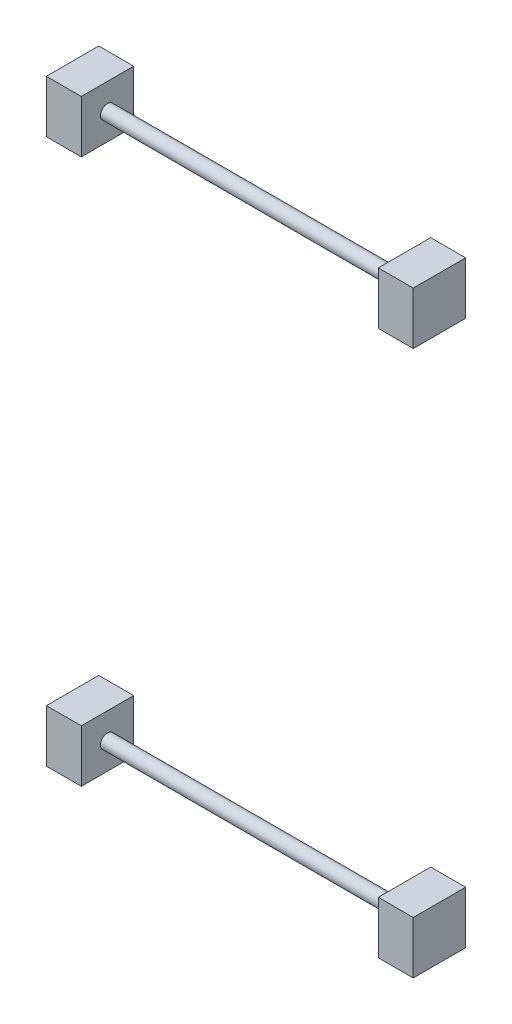
from build123d import *

# Parameters (mm, degrees)
SKETCH1_W           = 75
SKETCH1_H           = 75
SKETCH1_R           = 10
BOSS_EXTRUDE1_DEPTH = 50
LPATTERN1_COUNT     = 2
LPATTERN1_PITCH     = 475
SKETCH2_R           = 10
BOSS_EXTRUDE2_DEPTH = 525
LPATTERN2_COUNT     = 2
LPATTERN2_PITCH     = 780


with BuildPart() as part:
    # Sketch1 → Boss-Extrude1 (new body)
    with BuildSketch(Plane.ZY.offset(23475.561141738)):
        with Locations((40655.358832434, 5612.166693368)):
            Rectangle(SKETCH1_W, SKETCH1_H)
        with Locations((40655.358832434, 5612.166693368)):
            Circle(SKETCH1_R, mode=Mode.SUBTRACT)
    extrude(amount=-BOSS_EXTRUDE1_DEPTH)


with BuildPart() as lpattern1_1:
    # LPattern1: pattern copy
    add(part.part.moved(Location(Vector(1, 0, 0) * (1 * LPATTERN1_PITCH))))


with BuildPart() as part_1:
    add(part.part)

    add(lpattern1_1.part)  # Boss-Extrude2 merges LPattern1_1
    # Sketch2 → Boss-Extrude2 (add)
    with BuildSketch(Plane.ZY.offset(23475.561141738)):
        with Locations((40655.358832434, 5612.166693368)):
            Circle(SKETCH2_R)
    extrude(amount=-BOSS_EXTRUDE2_DEPTH)


with BuildPart() as lpattern2_1:
    # LPattern2: pattern copy
    add(part_1.part.moved(Location(Vector(0, 1, 0) * (1 * LPATTERN2_PITCH))))


solid = Compound([part_1.part, lpattern2_1.part])
